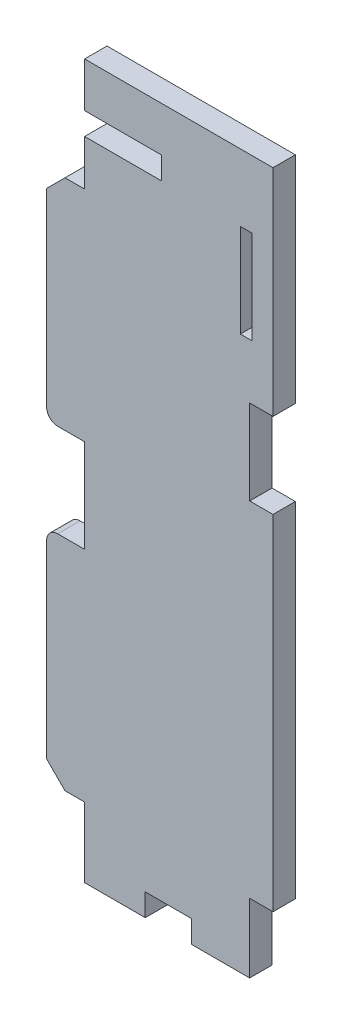
from build123d import *

# Parameters (mm, degrees)
MODEL_W             = 1.574799418
MODEL_H             = 12.699998915
BOSS_EXTRUDE1_DEPTH = 3.048


with BuildPart() as part:
    # Model → Boss-Extrude1 (new body)
    with BuildSketch(Plane.XY):
        with BuildLine():
            Line((15.63479994, 91.058996506), (5.17, 91.058996506))
            Line((5.17, 91.058996506), (5.17, 97.154987045))
            Line((5.17, 97.154987045), (30.823999648, 97.154987045))
            Line((30.823999648, 97.154987045), (30.823999648, 67.817998119))
            Line((30.823999648, 67.817998119), (27.648999919, 67.817998119))
            Line((27.648999919, 67.817998119), (27.648999919, 56.261000223))
            Line((27.648999919, 56.261000223), (30.823999648, 56.261000223))
            Line((30.823999648, 56.261000223), (30.823999648, 9.397999849))
            Line((30.823999648, 9.397999849), (27.648999919, 9.397999849))
            Line((27.648999919, 9.397999849), (27.648999919, 0))
            Line((27.648999919, 0), (19.724199181, 0))
            Line((19.724199181, 0), (19.724199181, 3.047999926))
            Line((19.724199181, 3.047999926), (13.424999644, 3.047999926))
            Line((13.424999644, 3.047999926), (13.424999644, 0))
            Line((13.424999644, 0), (5.17, 0))
            Line((5.17, 0), (5.17, 9.397999849))
            Line((5.17, 9.397999849), (5.17, 9.51))
            Line((5.17, 9.51), (2.5, 9.51))
            Line((2.5, 9.51), (0, 12.01))
            Line((0, 12.01), (0, 37.8165))
            ThreePointArc((0, 37.8165), (0.439339828, 38.877160172), (1.5, 39.3165))
            Line((1.5, 39.3165), (5.17, 39.3165))
            Line((5.17, 39.3165), (5.17, 51.9965))
            Line((5.17, 51.9965), (1.5, 51.9965))
            ThreePointArc((1.5, 51.9965), (0.439339828, 52.435839828), (0, 53.4965))
            Line((0, 53.4965), (0, 79.303))
            Line((0, 79.303), (2.5, 81.803))
            Line((2.5, 81.803), (5.17, 81.803))
            Line((5.17, 81.803), (5.17, 88.011001237))
            Line((5.17, 88.011001237), (15.63479994, 88.011001237))
            Line((15.63479994, 88.011001237), (15.63479994, 91.058996506))
        make_face()
        with Locations((27.166399737, 81.661001779)):
            Rectangle(MODEL_W, MODEL_H, mode=Mode.SUBTRACT)
    extrude(amount=BOSS_EXTRUDE1_DEPTH)


solid = part.part
